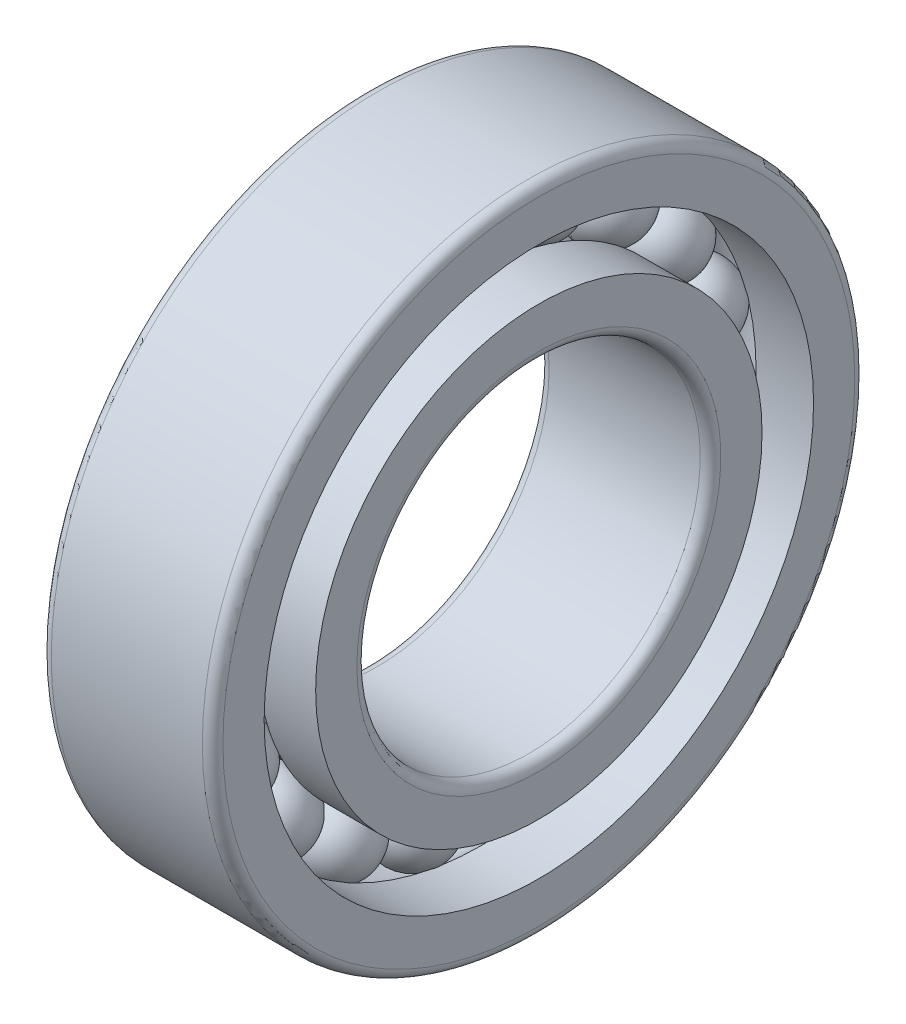
from build123d import *

# Parameters (mm, degrees)
CIRCULAR_PATTERN1_COUNT = 19
FILLET1_R               = 0.3


with BuildPart() as part:
    # Sketch1 → Revolve1 (revolve)
    with BuildSketch(Plane.XY):
        with BuildLine():
            Line((-1.125, 7.25), (1.125, 7.25))
            ThreePointArc((1.125, 7.25), (0, 8.375), (-1.125, 7.25))
        make_face()
    revolve1 = revolve(axis=Axis((-4.596601835, 7.25, 0), (1, 0, 0)))

    # Sketch2 → Revolve2 (revolve)
    with BuildSketch(Plane.XY, mode=Mode.PRIVATE) as revolve2_sk:
        with BuildLine():
            Line((-2.5, 6.5), (-2.5, 5))
            Line((-2.5, 5), (2.5, 5))
            Line((2.5, 5), (2.5, 6.5))
            Line((2.5, 6.5), (0.825060604, 6.5))
            ThreePointArc((0.825060604, 6.5), (0, 6.135), (-0.825060604, 6.5))
            Line((-0.825060604, 6.5), (-2.5, 6.5))
        make_face()
    revolve(revolve2_sk.sketch.rotate(Axis((-6.971390126, 0, 0), (1, 0, 0)), 90), axis=Axis((-6.971390126, 0, 0), (1, 0, 0)))

    # Sketch3 → Revolve3 (revolve)
    with BuildSketch(Plane.XY, mode=Mode.PRIVATE) as revolve3_sk:
        with BuildLine():
            Line((-2.5, 9.5), (2.5, 9.5))
            Line((2.5, 9.5), (2.5, 8))
            Line((2.5, 8), (0.825060604, 8))
            ThreePointArc((0.825060604, 8), (0, 8.365), (-0.825060604, 8))
            Line((-0.825060604, 8), (-2.5, 8))
            Line((-2.5, 8), (-2.5, 9.5))
        make_face()
    revolve(revolve3_sk.sketch.rotate(Axis((-8.710676495, 0, 0), (1, 0, 0)), 90), axis=Axis((-8.710676495, 0, 0), (1, 0, 0)))

    # Circular-Pattern1: Revolve1 ×19 about axis
    circular_pattern1_axis = Axis((0, 0, 0), (1, 0, 0))
    for i in range(1, CIRCULAR_PATTERN1_COUNT):
        add(revolve1.rotate(circular_pattern1_axis, i * 360 / CIRCULAR_PATTERN1_COUNT))

    # Fillet1
    fillet1_edges = [part.edges().sort_by_distance(p)[0] for p in [
        (-2.5, 0, -9.5),
        (2.5, 0, -9.5),
        (-2.5, 0, -5),
        (2.5, 0, -5),
    ]]
    fillet(fillet1_edges, radius=FILLET1_R)


solid = part.part
